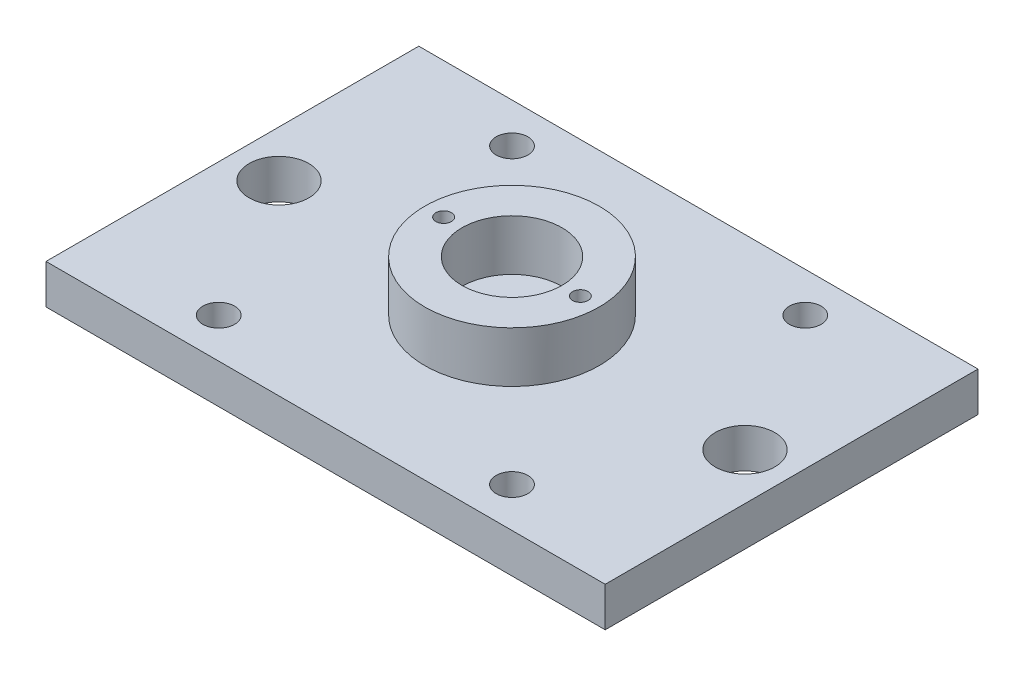
from build123d import *

# Parameters (mm, degrees)
SKETCH1_W           = 90
SKETCH1_H           = 60
SKETCH1_R           = 4.8
SKETCH1_R_2         = 2.55
BOSS_EXTRUDE1_DEPTH = 6.35
SKETCH2_R           = 14.05
SKETCH2_R_2         = 8.05
BOSS_EXTRUDE2_DEPTH = 8.175
SKETCH3_R           = 1.25
CUT_EXTRUDE1_DEPTH  = 8


with BuildPart() as part:
    # Sketch1 → Boss-Extrude1 (new body)
    with BuildSketch(Plane(origin=(0, 0, 0), x_dir=(1, 0, 0), z_dir=(0, 1, 0))):
        Rectangle(SKETCH1_W, SKETCH1_H)
        with Locations((-37.5, 0)):
            Circle(SKETCH1_R, mode=Mode.SUBTRACT)
        with Locations((37.5, 0)):
            Circle(SKETCH1_R, mode=Mode.SUBTRACT)
        with Locations((-23.6, -23.6)):
            Circle(SKETCH1_R_2, mode=Mode.SUBTRACT)
        with Locations((23.6, -23.6)):
            Circle(SKETCH1_R_2, mode=Mode.SUBTRACT)
        with Locations((23.6, 23.6)):
            Circle(SKETCH1_R_2, mode=Mode.SUBTRACT)
        with Locations((-23.6, 23.6)):
            Circle(SKETCH1_R_2, mode=Mode.SUBTRACT)
    extrude(amount=BOSS_EXTRUDE1_DEPTH)

    # Sketch2 → Boss-Extrude2 (add)
    with BuildSketch(Plane(origin=(0, 6.35, 0), x_dir=(1, 0, 0), z_dir=(0, 1, 0))):
        Circle(SKETCH2_R)
        Circle(SKETCH2_R_2, mode=Mode.SUBTRACT)
    extrude(amount=BOSS_EXTRUDE2_DEPTH)

    # Sketch3 → Cut-Extrude1 (cut)
    with BuildSketch(Plane(origin=(0, 14.525, 0), x_dir=(1, 0, 0), z_dir=(0, 1, 0))):
        with Locations((-11, 0)):
            Circle(SKETCH3_R)
        with Locations((11, 0)):
            Circle(SKETCH3_R)
    extrude(amount=-CUT_EXTRUDE1_DEPTH, mode=Mode.SUBTRACT)


solid = part.part
